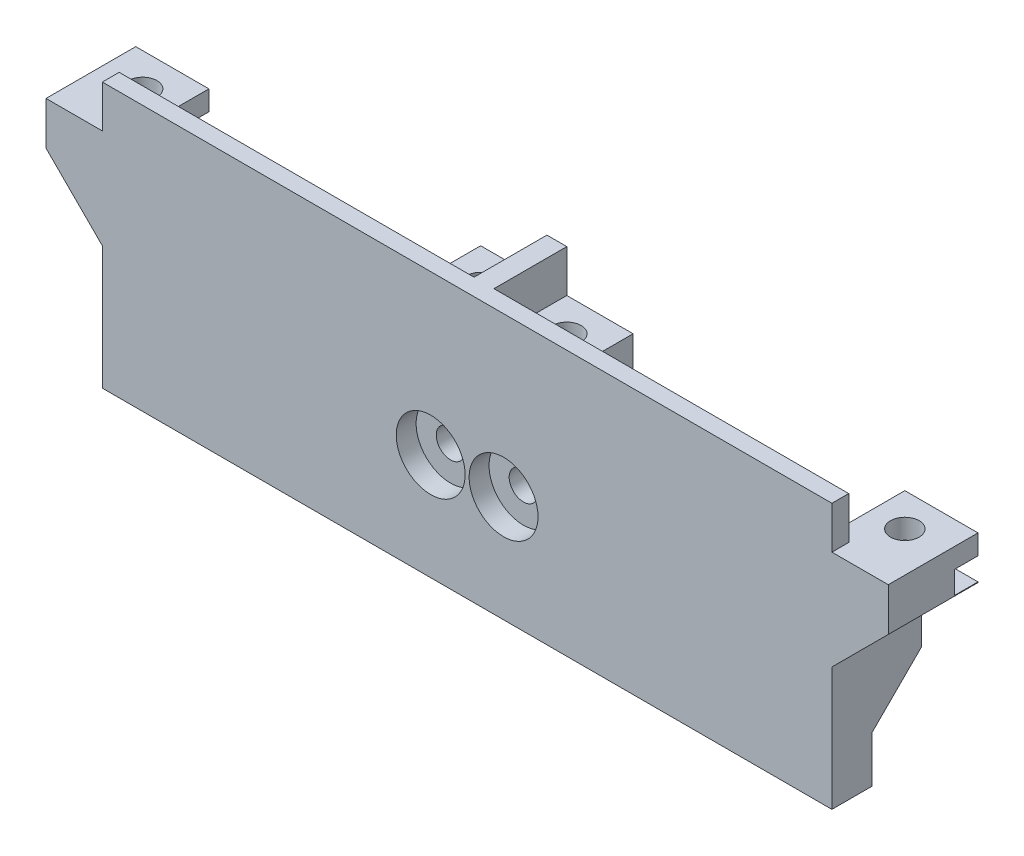
from build123d import *

# Parameters (mm, degrees)
SKETCH1_R               = 2.16
BOSS_EXTRUDE1_DEPTH     = 26.61
CUT_EXTRUDE1_DEPTH      = 3.5
CUT_EXTRUDE2_DEPTH      = 4
SKETCH5_W               = 110.08
SKETCH5_H               = 13.54
SKETCH5_R               = 2.16
BOSS_EXTRUDE2_DEPTH     = 7
BOSS_EXTRUDE3_DEPTH     = 6.39
BOSS_EXTRUDE4_DEPTH     = 13.54
CUT_EXTRUDE3_START      = -1.4
SKETCH8_R               = 2.16
CUT_EXTRUDE3_DEPTH      = 3.4
CUT_EXTRUDE4_START      = -29.61
SKETCH8_2_R             = 2.16
CUT_EXTRUDE4_DEPTH      = 42
CHAMFER2_SIZE           = 2
SKETCH10_R              = 2.16
CUT_EXTRUDE5_DEPTH      = 1
CUT_EXTRUDE5_DEPTH_BACK = 14.54
SKETCH10_3_R            = 5.196152423
CUT_EXTRUDE6_DEPTH      = 3
SKETCH11_W              = 27.08
SKETCH11_H              = 7
CUT_EXTRUDE7_DEPTH      = 7.5
SKETCH11_3_W            = 27.08
SKETCH11_3_H            = 7
BOSS_EXTRUDE5_DEPTH     = 7.5
SKETCH12_R              = 3.55
CUT_EXTRUDE8_DEPTH      = 7.5


with BuildPart() as part:
    # Sketch1 → Boss-Extrude1 (new body)
    with BuildSketch(Plane(origin=(0, 0, 0), x_dir=(1, 0, 0), z_dir=(0, 1, 0))):
        Polygon((-23.04, -8.04), (-23.04, 5.5), (-20.5, 5.5), (-20.5, -5.5), (20.5, -5.5), (20.5, 5.5), (23.04, 5.5), (40.96, 5.5), (43.5, 5.5), (43.5, -5.5), (84.5, -5.5), (84.5, 5.5), (87.04, 5.5), (87.04, -8.04), (40.96, -8.04), (23.04, -8.04), align=None)
        with Locations((25.5, 0.5)):
            Circle(SKETCH1_R, mode=Mode.SUBTRACT)
        with Locations((38.5, 0.5)):
            Circle(SKETCH1_R, mode=Mode.SUBTRACT)
    extrude(amount=BOSS_EXTRUDE1_DEPTH)

    # Sketch3 → Cut-Extrude1 (cut)
    with BuildSketch(Plane(origin=(0, 21.61, 0), x_dir=(1, 0, 0), z_dir=(0, 1, 0))):
        Polygon((28.098076211, -4), (30.696152423, 0.5), (28.098076211, 5), (27.809401077, 5.5), (20.5, 5.5), (20.5, -4), (22.901923789, -4), align=None)
        Polygon((35.901923789, 5), (33.303847577, 0.5), (35.901923789, -4), (41.098076211, -4), (43.5, -4), (43.5, 5.5), (36.190598923, 5.5), align=None)
    extrude(amount=-CUT_EXTRUDE1_DEPTH, mode=Mode.SUBTRACT)

    # Sketch4 → Cut-Extrude2 (cut)
    with BuildSketch(Plane.ZY.offset(23.04)):
        Polygon((-5.5, 7.5), (2, 0), (-5.5, 0), align=None)
    cut_extrude2 = extrude(amount=-CUT_EXTRUDE2_DEPTH, mode=Mode.SUBTRACT)

    # Mirror1: Cut-Extrude2 across plane
    add(cut_extrude2.mirror(Plane(origin=(32, 0, 0), x_dir=(0, 0, 1), z_dir=(1, 0, 0))), mode=Mode.SUBTRACT)

    # Sketch5 → Boss-Extrude2 (add)
    with BuildSketch(Plane.XZ):
        with Locations((32, 1.27)):
            Rectangle(SKETCH5_W, SKETCH5_H)
        with Locations((38.5, -0.5)):
            Circle(SKETCH5_R, mode=Mode.SUBTRACT)
        with Locations((25.5, -0.5)):
            Circle(SKETCH5_R, mode=Mode.SUBTRACT)
    extrude(amount=BOSS_EXTRUDE2_DEPTH)

    # Sketch6 → Boss-Extrude3 (add)
    with BuildSketch(Plane(origin=(0, 26.61, 0), x_dir=(1, 0, 0), z_dir=(0, 1, 0))):
        Polygon((-23.04, -5.5), (30.5, -5.5), (30.5, 5.5), (33.5, 5.5), (33.5, -5.5), (87.04, -5.5), (87.04, -8.04), (-23.04, -8.04), align=None)
    extrude(amount=BOSS_EXTRUDE3_DEPTH)

    # Sketch7 → Boss-Extrude4 (add)
    with BuildSketch(Plane.XY.offset(8.04)):
        Polygon((-23.04, 26.61), (-31.54, 26.61), (-31.54, 20.11), (-23.04, 11.61), align=None)
    boss_extrude4 = extrude(amount=-BOSS_EXTRUDE4_DEPTH)

    # Sketch8 → Cut-Extrude3 (cut)
    with BuildSketch(Plane(origin=(0, 21.61, 0), x_dir=(1, 0, 0), z_dir=(0, 1, 0)).offset(CUT_EXTRUDE3_START)):
        Polygon((-30.696152423, 0.5), (-31.54, 1.961586878), (-31.54, 5.5), (-20.5, 5.5), (-20.5, 0.160254038), (-22.901923789, -4), (-28.098076211, -4), align=None)
        with Locations((-25.5, 0.5)):
            Circle(SKETCH8_R, mode=Mode.SUBTRACT)
    cut_extrude3 = extrude(amount=CUT_EXTRUDE3_DEPTH, mode=Mode.SUBTRACT)

    # Sketch8_2 → Cut-Extrude4 (cut)
    with BuildSketch(Plane(origin=(0, 21.61, 0), x_dir=(1, 0, 0), z_dir=(0, 1, 0)).offset(CUT_EXTRUDE4_START)):
        with Locations((-25.5, 0.5)):
            Circle(SKETCH8_2_R)
    cut_extrude4 = extrude(amount=CUT_EXTRUDE4_DEPTH, mode=Mode.SUBTRACT)

    # Mirror2: Boss-Extrude4, Cut-Extrude3, Cut-Extrude4 across plane
    add(boss_extrude4.mirror(Plane(origin=(32, 0, 0), x_dir=(0, 0, 1), z_dir=(1, 0, 0))))
    add(cut_extrude3.mirror(Plane(origin=(32, 0, 0), x_dir=(0, 0, 1), z_dir=(1, 0, 0))), mode=Mode.SUBTRACT)
    add(cut_extrude4.mirror(Plane(origin=(32, 0, 0), x_dir=(0, 0, 1), z_dir=(1, 0, 0))), mode=Mode.SUBTRACT)

    # Chamfer2
    chamfer2_edges = [part.edges().sort_by_distance(p)[0] for p in [
        (84.5, 3.75, -1.75),
        (-20.5, 3.75, -1.75),
    ]]
    chamfer(chamfer2_edges, length=CHAMFER2_SIZE)

    # Sketch10 → Cut-Extrude5 (cut, two sides)
    with BuildSketch(Plane.XY.offset(8.04)) as cut_extrude5_sk:
        with Locations((26.5, 9.055)):
            Circle(SKETCH10_R)
        with Locations((37.5, 9.055)):
            Circle(SKETCH10_R)
    extrude(amount=CUT_EXTRUDE5_DEPTH, mode=Mode.SUBTRACT)
    extrude(cut_extrude5_sk.sketch, amount=-CUT_EXTRUDE5_DEPTH_BACK, mode=Mode.SUBTRACT)

    # Sketch10_3 → Cut-Extrude6 (cut)
    with BuildSketch(Plane.XY.offset(8.04)):
        with Locations((26.5, 9.055)):
            Circle(SKETCH10_3_R)
        with Locations((37.5, 9.055)):
            Circle(SKETCH10_3_R)
    extrude(amount=-CUT_EXTRUDE6_DEPTH, mode=Mode.SUBTRACT)

    # Sketch11 → Cut-Extrude7 (cut)
    with BuildSketch(Plane(origin=(0, 0, -5.5), x_dir=(-1, 0, 0), z_dir=(0, 0, -1))):
        with Locations((-73.5, -3.5)):
            Rectangle(SKETCH11_W, SKETCH11_H)
    extrude(amount=-CUT_EXTRUDE7_DEPTH, mode=Mode.SUBTRACT)

    # Sketch11_3 → Boss-Extrude5 (add)
    with BuildSketch(Plane(origin=(0, 0, -5.5), x_dir=(-1, 0, 0), z_dir=(0, 0, -1))):
        with Locations((9.5, -3.5)):
            Rectangle(SKETCH11_3_W, SKETCH11_3_H)
    extrude(amount=BOSS_EXTRUDE5_DEPTH)

    # Sketch12 → Cut-Extrude8 (cut)
    with BuildSketch(Plane.XZ.offset(7)):
        with Locations((-9.5, -5.5)):
            Circle(SKETCH12_R)
    extrude(amount=-CUT_EXTRUDE8_DEPTH, mode=Mode.SUBTRACT)


solid = part.part
